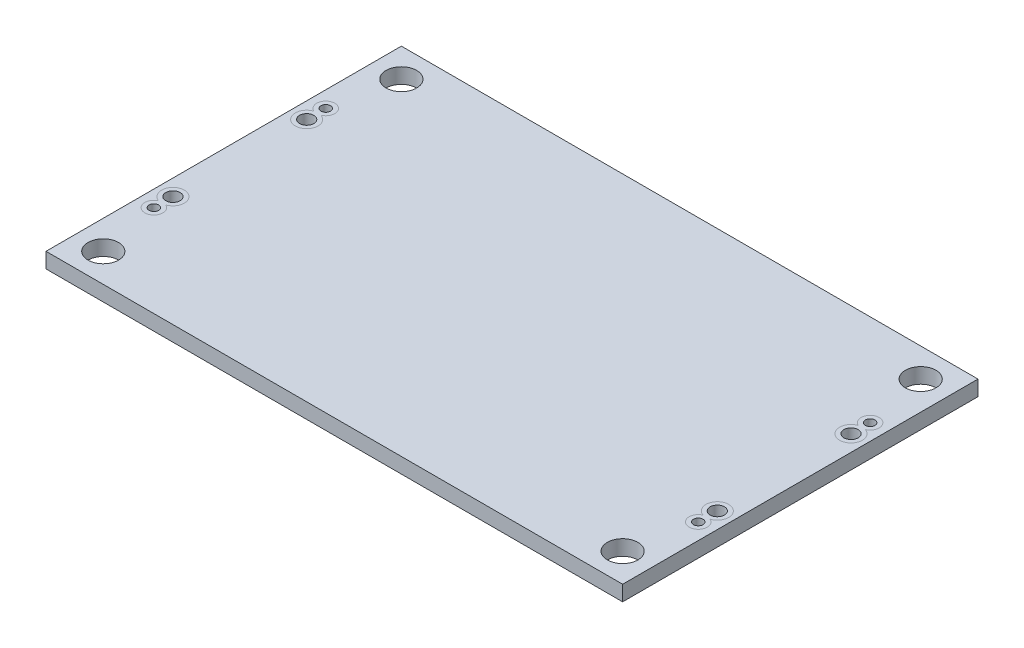
from build123d import *

# Parameters (mm, degrees)
SKETCH1_W                = 60.38
SKETCH1_H                = 37.21
BOSS_EXTRUDE1_DEPTH      = 1.6
M3_CLEARANCE_HOLE1_D     = 3.2
MIRROR2_COPY_1_D         = 3.2
SKETCH4_R                = 0.75
SKETCH4_R_2              = 0.5
CUT_EXTRUDE1_DEPTH       = 36.498480601
SPLIT1_SURFACE_1_1_BACK  = 71.943
SPLIT1_SURFACE_1_1_DEPTH = 143.886
SPLIT1_SURFACE_1_2_BACK  = 71.943
SPLIT1_SURFACE_1_2_DEPTH = 143.886
SPLIT1_SURFACE_2_3_BACK  = 71.943
SPLIT1_SURFACE_2_3_DEPTH = 143.886
SPLIT1_SURFACE_2_4_BACK  = 71.943
SPLIT1_SURFACE_2_4_DEPTH = 143.886
SPLIT1_SURFACE_3_5_BACK  = 71.943
SPLIT1_SURFACE_3_5_DEPTH = 143.886
SPLIT1_SURFACE_3_6_BACK  = 71.943
SPLIT1_SURFACE_3_6_DEPTH = 143.886
SPLIT1_SURFACE_4_7_BACK  = 71.943
SPLIT1_SURFACE_4_7_DEPTH = 143.886
SPLIT1_SURFACE_4_8_BACK  = 71.943
SPLIT1_SURFACE_4_8_DEPTH = 143.886


with BuildPart() as part:
    # Sketch1 → Boss-Extrude1 (new body)
    with BuildSketch(Plane(origin=(0, 0, 0), x_dir=(1, 0, 0), z_dir=(0, 1, 0))):
        Rectangle(SKETCH1_W, SKETCH1_H)
    extrude(amount=BOSS_EXTRUDE1_DEPTH)

    # M3 Clearance Hole1 (through all)
    with Locations(Plane(origin=(0, 1.6, 0), x_dir=(1, 0, 0), z_dir=(0, 1, 0))):
        with Locations((-27.19, 15.605)):
            m3_clearance_hole1 = Hole(M3_CLEARANCE_HOLE1_D / 2)

    # Mirror1: M3 Clearance Hole1 across plane
    add(m3_clearance_hole1.mirror(Plane(origin=(0, 0, 0), x_dir=(0, 0, 1), z_dir=(1, 0, 0))), mode=Mode.SUBTRACT)

    # Mirror2: M3 Clearance Hole1 across plane
    add(m3_clearance_hole1.mirror(Plane.XY), mode=Mode.SUBTRACT)

    # Mirror2 copy 1 (through all)
    with Locations(Plane(origin=(0, 1.6, 0), x_dir=(-1, 0, 0), z_dir=(0, 1, 0))):
        with Locations((-27.19, 15.605)):
            Hole(MIRROR2_COPY_1_D / 2)

    # Sketch4 → Cut-Extrude1 (cut, through all)
    with BuildSketch(Plane(origin=(0, 1.6, 0), x_dir=(1, 0, 0), z_dir=(0, 1, 0))):
        with Locations(Location((28.5, 7, 0), (0, 0, 270))):
            Circle(SKETCH4_R)
        with Locations(Location((28.5, -7, 0), (0, 0, 270))):
            Circle(SKETCH4_R)
        with Locations(Location((-28.5, -7, 0), (0, 0, 270))):
            Circle(SKETCH4_R)
        with Locations(Location((-28.5, 7, 0), (0, 0, 270))):
            Circle(SKETCH4_R)
        with Locations(Location((-28.5, 9, 0), (0, 0, 270))):
            Circle(SKETCH4_R_2)
        with Locations(Location((28.5, 9, 0), (0, 0, 270))):
            Circle(SKETCH4_R_2)
        with Locations(Location((28.5, -9, 0), (0, 0, 270))):
            Circle(SKETCH4_R_2)
        with Locations(Location((-28.5, -9, 0), (0, 0, 270))):
            Circle(SKETCH4_R_2)
    extrude(amount=-CUT_EXTRUDE1_DEPTH, mode=Mode.SUBTRACT)


with BuildPart() as body_2:
    # Split1: the piece behind the surface
    add(part.part)
    # Split1 surface 1: a surface, the sketch's curves swept straight by 143.886 mm
    with BuildLine(Plane(origin=(0, 1.6, 0), x_dir=(1, 0, 0), z_dir=(0, 1, 0)).offset(-SPLIT1_SURFACE_1_1_BACK), mode=Mode.PRIVATE) as split1_surface_1_1_path:
        ThreePointArc((-28.867338087, 8.128907093), (-28.5, 5.812831733), (-28.132661913, 8.128907093))
        ThreePointArc((-28.132661913, 8.128907093), (-28.5, 9.945378296), (-28.867338087, 8.128907093))
    split1_surface_1_1 = Shell.extrude(split1_surface_1_1_path.wire(), (0 * SPLIT1_SURFACE_1_1_DEPTH, 1 * SPLIT1_SURFACE_1_1_DEPTH, 0 * SPLIT1_SURFACE_1_1_DEPTH))
    split(bisect_by=split1_surface_1_1, keep=Keep.BOTTOM)


with BuildPart() as part_1:
    add(part.part)

    # Split1: split by a surface, the side it looks to stays
    # Split1 surface 1: a surface, the sketch's curves swept straight by 143.886 mm
    with BuildLine(Plane(origin=(0, 1.6, 0), x_dir=(1, 0, 0), z_dir=(0, 1, 0)).offset(-SPLIT1_SURFACE_1_2_BACK), mode=Mode.PRIVATE) as split1_surface_1_2_path:
        ThreePointArc((-28.867338087, 8.128907093), (-28.5, 5.812831733), (-28.132661913, 8.128907093))
        ThreePointArc((-28.132661913, 8.128907093), (-28.5, 9.945378296), (-28.867338087, 8.128907093))
    split1_surface_1_2 = Shell.extrude(split1_surface_1_2_path.wire(), (0 * SPLIT1_SURFACE_1_2_DEPTH, 1 * SPLIT1_SURFACE_1_2_DEPTH, 0 * SPLIT1_SURFACE_1_2_DEPTH))
    split(bisect_by=split1_surface_1_2, keep=Keep.TOP)


with BuildPart() as body_3:
    # Split1 2 body 2: the piece behind the surface
    add(body_2.part)
    # Split1 surface 2: a surface, the sketch's curves swept straight by 143.886 mm
    with BuildLine(Plane(origin=(0, 1.6, 0), x_dir=(1, 0, 0), z_dir=(0, 1, 0)).offset(-SPLIT1_SURFACE_2_3_BACK), mode=Mode.PRIVATE) as split1_surface_2_3_path:
        ThreePointArc((28.132661913, 8.128907093), (28.5, 9.945378296), (28.867338087, 8.128907093))
        ThreePointArc((28.867338087, 8.128907093), (28.5, 5.812831733), (28.132661913, 8.128907093))
    split1_surface_2_3 = Shell.extrude(split1_surface_2_3_path.wire(), (0 * SPLIT1_SURFACE_2_3_DEPTH, 1 * SPLIT1_SURFACE_2_3_DEPTH, 0 * SPLIT1_SURFACE_2_3_DEPTH))
    split(bisect_by=split1_surface_2_3, keep=Keep.BOTTOM)


with BuildPart() as body_2_1:
    add(body_2.part)

    # Split1 2 body 2: split by a surface, the side it looks to stays
    # Split1 surface 2: a surface, the sketch's curves swept straight by 143.886 mm
    with BuildLine(Plane(origin=(0, 1.6, 0), x_dir=(1, 0, 0), z_dir=(0, 1, 0)).offset(-SPLIT1_SURFACE_2_4_BACK), mode=Mode.PRIVATE) as split1_surface_2_4_path:
        ThreePointArc((28.132661913, 8.128907093), (28.5, 9.945378296), (28.867338087, 8.128907093))
        ThreePointArc((28.867338087, 8.128907093), (28.5, 5.812831733), (28.132661913, 8.128907093))
    split1_surface_2_4 = Shell.extrude(split1_surface_2_4_path.wire(), (0 * SPLIT1_SURFACE_2_4_DEPTH, 1 * SPLIT1_SURFACE_2_4_DEPTH, 0 * SPLIT1_SURFACE_2_4_DEPTH))
    split(bisect_by=split1_surface_2_4, keep=Keep.TOP)


with BuildPart() as body_4:
    # Split1 3 body 2: the piece behind the surface
    add(body_2_1.part)
    # Split1 surface 3: a surface, the sketch's curves swept straight by 143.886 mm
    with BuildLine(Plane(origin=(0, 1.6, 0), x_dir=(1, 0, 0), z_dir=(0, 1, 0)).offset(-SPLIT1_SURFACE_3_5_BACK), mode=Mode.PRIVATE) as split1_surface_3_5_path:
        ThreePointArc((-28.132661913, -8.128907093), (-28.5, -9.945378296), (-28.867338087, -8.128907093))
        ThreePointArc((-28.867338087, -8.128907093), (-28.5, -5.812831733), (-28.132661913, -8.128907093))
    split1_surface_3_5 = Shell.extrude(split1_surface_3_5_path.wire(), (0 * SPLIT1_SURFACE_3_5_DEPTH, 1 * SPLIT1_SURFACE_3_5_DEPTH, 0 * SPLIT1_SURFACE_3_5_DEPTH))
    split(bisect_by=split1_surface_3_5, keep=Keep.BOTTOM)


with BuildPart() as body_2_2:
    add(body_2_1.part)

    # Split1 3 body 2: split by a surface, the side it looks to stays
    # Split1 surface 3: a surface, the sketch's curves swept straight by 143.886 mm
    with BuildLine(Plane(origin=(0, 1.6, 0), x_dir=(1, 0, 0), z_dir=(0, 1, 0)).offset(-SPLIT1_SURFACE_3_6_BACK), mode=Mode.PRIVATE) as split1_surface_3_6_path:
        ThreePointArc((-28.132661913, -8.128907093), (-28.5, -9.945378296), (-28.867338087, -8.128907093))
        ThreePointArc((-28.867338087, -8.128907093), (-28.5, -5.812831733), (-28.132661913, -8.128907093))
    split1_surface_3_6 = Shell.extrude(split1_surface_3_6_path.wire(), (0 * SPLIT1_SURFACE_3_6_DEPTH, 1 * SPLIT1_SURFACE_3_6_DEPTH, 0 * SPLIT1_SURFACE_3_6_DEPTH))
    split(bisect_by=split1_surface_3_6, keep=Keep.TOP)


with BuildPart() as body_5_2:
    # Split1 4 body 2: the piece behind the surface
    add(body_2_2.part)
    # Split1 surface 4: a surface, the sketch's curves swept straight by 143.886 mm
    with BuildLine(Plane(origin=(0, 1.6, 0), x_dir=(1, 0, 0), z_dir=(0, 1, 0)).offset(-SPLIT1_SURFACE_4_7_BACK), mode=Mode.PRIVATE) as split1_surface_4_7_path:
        ThreePointArc((28.867338087, -8.128907093), (28.5, -5.812831733), (28.132661913, -8.128907093))
        ThreePointArc((28.132661913, -8.128907093), (28.5, -9.945378296), (28.867338087, -8.128907093))
    split1_surface_4_7 = Shell.extrude(split1_surface_4_7_path.wire(), (0 * SPLIT1_SURFACE_4_7_DEPTH, 1 * SPLIT1_SURFACE_4_7_DEPTH, 0 * SPLIT1_SURFACE_4_7_DEPTH))
    split(bisect_by=split1_surface_4_7, keep=Keep.BOTTOM)


with BuildPart() as body_2_3:
    add(body_2_2.part)

    # Split1 4 body 2: split by a surface, the side it looks to stays
    # Split1 surface 4: a surface, the sketch's curves swept straight by 143.886 mm
    with BuildLine(Plane(origin=(0, 1.6, 0), x_dir=(1, 0, 0), z_dir=(0, 1, 0)).offset(-SPLIT1_SURFACE_4_8_BACK), mode=Mode.PRIVATE) as split1_surface_4_8_path:
        ThreePointArc((28.867338087, -8.128907093), (28.5, -5.812831733), (28.132661913, -8.128907093))
        ThreePointArc((28.132661913, -8.128907093), (28.5, -9.945378296), (28.867338087, -8.128907093))
    split1_surface_4_8 = Shell.extrude(split1_surface_4_8_path.wire(), (0 * SPLIT1_SURFACE_4_8_DEPTH, 1 * SPLIT1_SURFACE_4_8_DEPTH, 0 * SPLIT1_SURFACE_4_8_DEPTH))
    split(bisect_by=split1_surface_4_8, keep=Keep.TOP)


solid = Compound([part_1.part, body_3.part, body_4.part, body_5_2.part, body_2_3.part])
